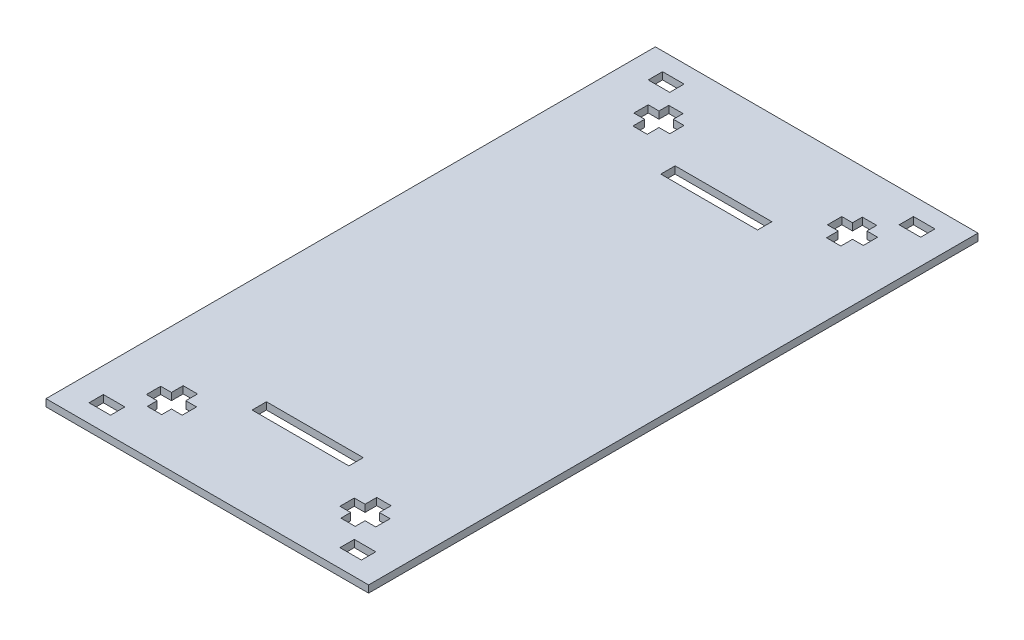
from build123d import *

# Parameters (mm, degrees)
SKETCH_1_W      = 90
SKETCH_1_H      = 170
SKETCH_1_W_2    = 27
SKETCH_1_H_2    = 4
EXTRUDE_1_DEPTH = 2


with BuildPart() as part:
    # 草图1 → 凸台-拉伸1 (new body)
    with BuildSketch(Plane(origin=(0, 0, 0), x_dir=(1, 0, 0), z_dir=(0, 1, 0))):
        Rectangle(SKETCH_1_W, SKETCH_1_H)
        Polygon((-29, -66), (-29, -62.731088435), (-25, -62.731088435), (-25, -66), (-22, -66), (-22, -70), (-25, -70), (-25, -72.731088435), (-29, -72.731088435), (-29, -70), (-32, -70), (-32, -66), align=None, mode=Mode.SUBTRACT)
        Polygon((29, -72.731088435), (29, -70), (32, -70), (32, -66), (29, -66), (29, -62.731088435), (25, -62.731088435), (25, -66), (22, -66), (22, -70), (25, -70), (25, -72.731088435), align=None, mode=Mode.SUBTRACT)
        Polygon((25, 72.731088435), (29, 72.731088435), (29, 70), (32, 70), (32, 66), (29, 66), (29, 62.731088435), (25, 62.731088435), (25, 66), (22, 66), (22, 70), (25, 70), align=None, mode=Mode.SUBTRACT)
        Polygon((-29, 72.731088435), (-29, 70), (-32, 70), (-32, 66), (-29, 66), (-29, 62.731088435), (-25, 62.731088435), (-25, 66), (-22, 66), (-22, 70), (-25, 70), (-25, 72.731088435), align=None, mode=Mode.SUBTRACT)
        Polygon((35, -80), (38, -80), (38, -76), (32, -76), (32, -80), align=None, mode=Mode.SUBTRACT)
        Polygon((-32, -76), (-32, -80), (-35, -80), (-38, -80), (-38, -76), align=None, mode=Mode.SUBTRACT)
        Polygon((32, 76), (32, 80), (35, 80), (38, 80), (38, 76), align=None, mode=Mode.SUBTRACT)
        Polygon((-38, 76), (-32, 76), (-32, 80), (-35, 80), (-38, 80), align=None, mode=Mode.SUBTRACT)
        with Locations((0, 57)):
            Rectangle(SKETCH_1_W_2, SKETCH_1_H_2, mode=Mode.SUBTRACT)
        with Locations((0, -57)):
            Rectangle(SKETCH_1_W_2, SKETCH_1_H_2, mode=Mode.SUBTRACT)
    extrude(amount=EXTRUDE_1_DEPTH)


solid = part.part
